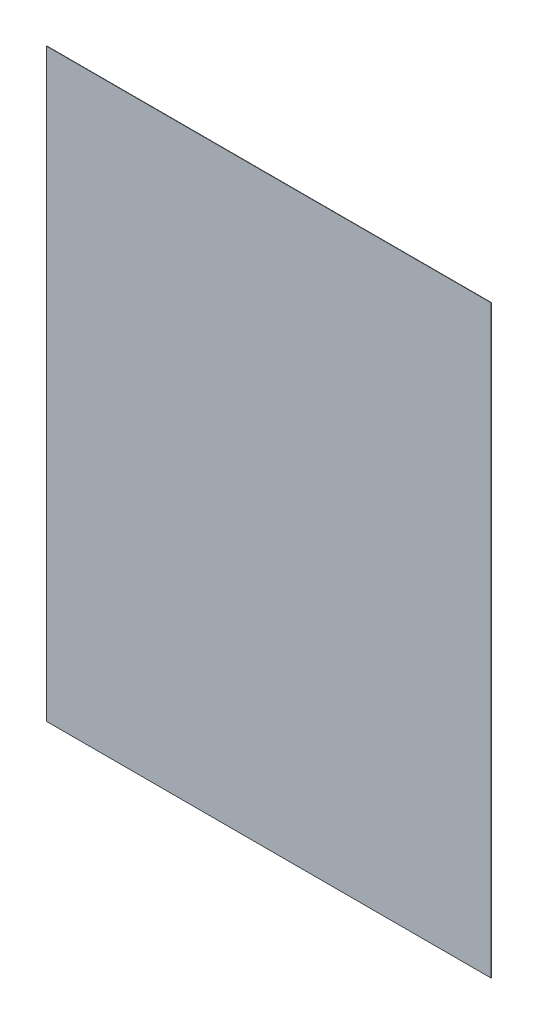
from build123d import *

# Parameters (mm, degrees)
SKETCH1_W      = 156.1
SKETCH1_H      = 205.5
NEGATIVE_DEPTH = 0.1159


with BuildPart() as part:
    # Sketch1 → Negative (new body)
    with BuildSketch(Plane.XY):
        Rectangle(SKETCH1_W, SKETCH1_H)
    extrude(amount=NEGATIVE_DEPTH)


solid = part.part
